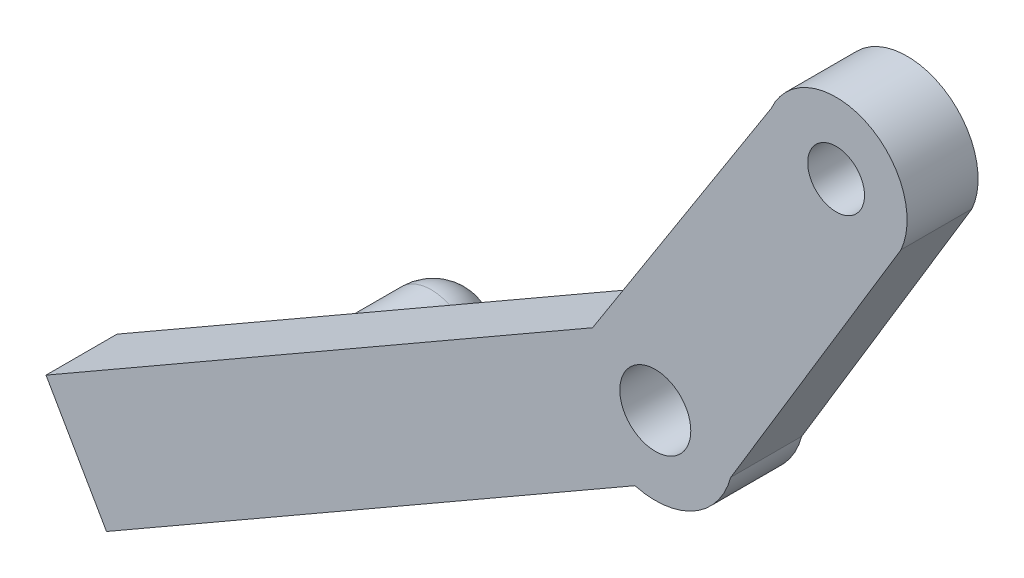
from build123d import *

# Parameters (mm, degrees)
SKETCH1_R           = 2
SKETCH1_R_2         = 2.5
BOSS_EXTRUDE1_DEPTH = 5
SKETCH8_R           = 3
BOSS_EXTRUDE3_DEPTH = 10


with BuildPart() as part:
    # Sketch1 → Boss-Extrude1 (new body)
    with BuildSketch(Plane(origin=(0, 0, 0), x_dir=(0.498528904, -0.866873077, 0), z_dir=(0, 0, 1))):
        with BuildLine():
            Line((8.899126574, 3.869128256), (-2.35642803, 24.179978159))
            ThreePointArc((-2.35642803, 24.179978159), (-9.345167797, 25.255857552), (-10.421047189, 18.267117784))
            Line((-10.421047189, 18.267117784), (1.120951981, -3.909046337))
            ThreePointArc((1.120951981, -3.909046337), (8.899126574, -3.909046337), (8.899126574, 3.869128256))
        make_face()
        with Locations((-6.38873761, 21.223547972)):
            Circle(SKETCH1_R, mode=Mode.SUBTRACT)
        with Locations((5.010039278, -0.019959041)):
            Circle(SKETCH1_R_2, mode=Mode.SUBTRACT)
        with BuildLine():
            Line((8.899126574, -46.838046337), (8.899126574, -3.909046337))
            ThreePointArc((8.899126574, -3.909046337), (5.010039278, -5.519959041), (1.120951981, -3.909046337))
            Line((1.120951981, -3.909046337), (0.353553391, -2.434608777))
            Line((0.353553391, -2.434608777), (0.353553391, -46.838046337))
            Line((0.353553391, -46.838046337), (8.899126574, -46.838046337))
        make_face()
    extrude(amount=BOSS_EXTRUDE1_DEPTH)

    # Sketch8 → Boss-Extrude3 (add)
    with BuildSketch(Plane(origin=(0, 0, 0), x_dir=(-1, 0, 0), z_dir=(0, 0, -1))):
        with Locations((25.293181008, -19.882635909)):
            Circle(SKETCH8_R)
    extrude(amount=BOSS_EXTRUDE3_DEPTH)

    # Sketch9 → Cut-Revolve1 (revolve, cut)
    with BuildSketch(Plane(origin=(2.306364199, -4.010449578, 0), x_dir=(-0.866873077, -0.498528904, 0), z_dir=(0.498528904, -0.866873077, 0))):
        with BuildLine():
            Line((32.838046337, 10), (34.838046337, 10))
            Line((34.838046337, 10), (34.838046337, 7))
            ThreePointArc((34.838046337, 7), (34.292209794, 8.802775638), (32.838046337, 10))
        make_face()
    revolve(axis=Axis((-25.293181008, -19.882635909, -10), (0, 0, 1)), mode=Mode.SUBTRACT)


solid = part.part
